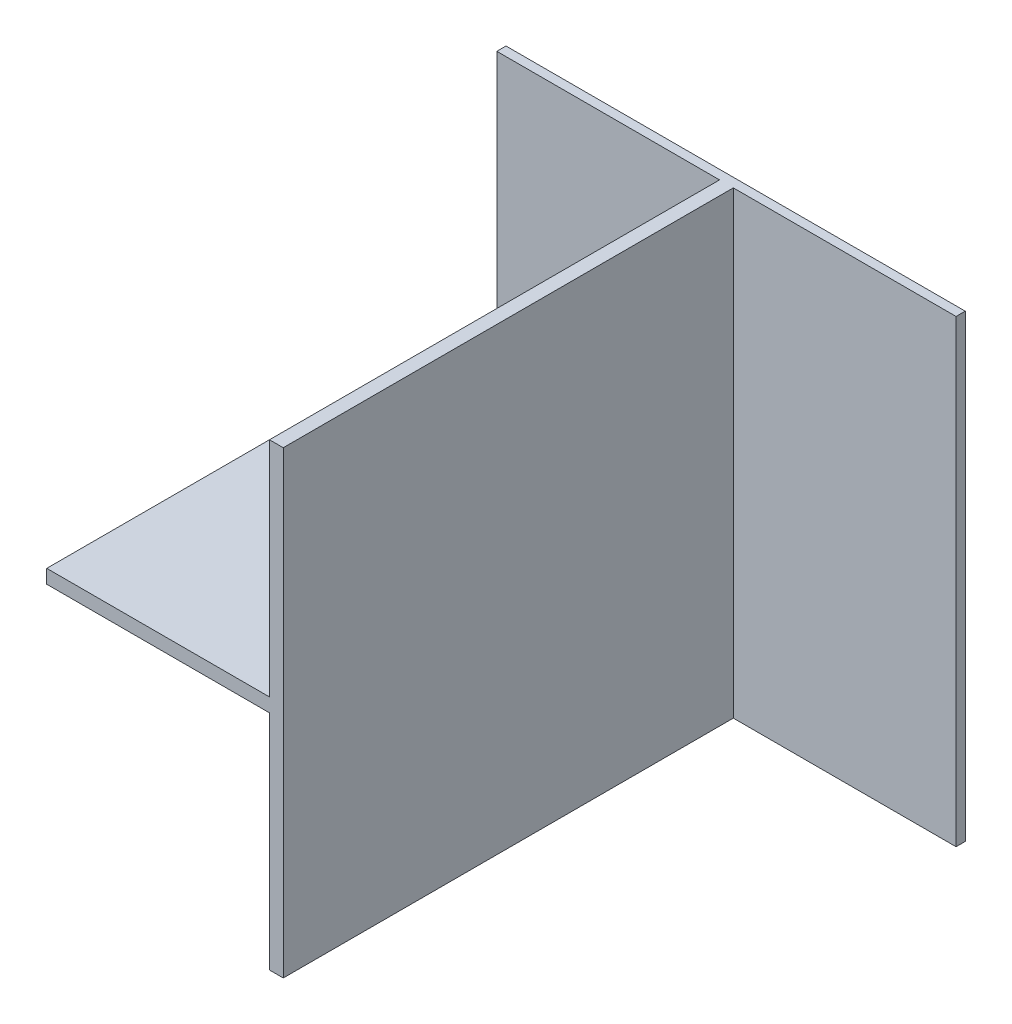
from build123d import *

# Parameters (mm, degrees)
SZKIC1_W                    = 100
SZKIC1_H                    = 100
DODANIE_WYCI_GNI_CIE1_DEPTH = 4
SZKIC2_W                    = 97
SZKIC2_H                    = 3
DODANIE_WYCI_GNI_CIE2_DEPTH = 200


with BuildPart() as part:
    # Szkic1 → Dodanie-wyciągnięcie1 (new body)
    with BuildSketch(Plane.XY):
        with Locations((-50, 50)):
            Rectangle(SZKIC1_W, SZKIC1_H)
        with Locations((50, 50)):
            Rectangle(SZKIC1_W, SZKIC1_H)
        with Locations((50, -50)):
            Rectangle(SZKIC1_W, SZKIC1_H)
        with Locations((-50, -50)):
            Rectangle(SZKIC1_W, SZKIC1_H)
    extrude(amount=DODANIE_WYCI_GNI_CIE1_DEPTH)

    # Szkic2 → Dodanie-wyciągnięcie2 (add)
    with BuildSketch(Plane.XY):
        with Locations((-51.5, 1.5)):
            Rectangle(SZKIC2_W, SZKIC2_H)
        with Locations((-51.5, -1.5)):
            Rectangle(SZKIC2_W, SZKIC2_H)
        Polygon((3, 100), (0, 100), (0, 0), (0, -100), (3, -100), align=None)
        Polygon((0, 0), (0, 100), (-3, 100), (-3, 3), (-3, 0), align=None)
        Polygon((0, -100), (0, 0), (-3, 0), (-3, -3), (-3, -100), align=None)
    extrude(amount=DODANIE_WYCI_GNI_CIE2_DEPTH)


solid = part.part
